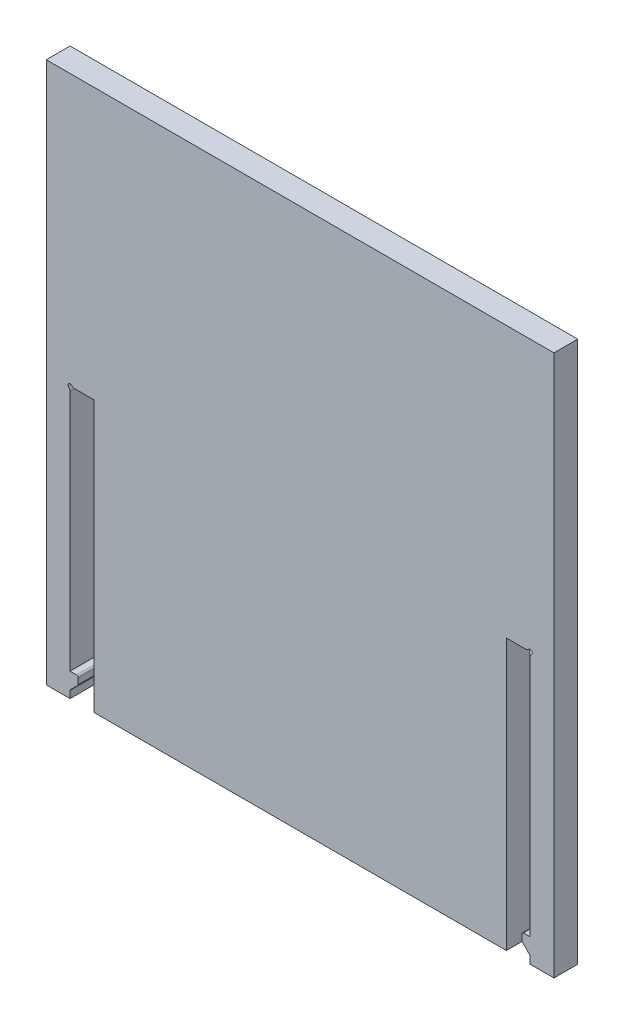
from build123d import *

# Parameters (mm, degrees)
SKETCH1_W            = 62.519999928
SKETCH1_H            = 66.675
BOSS_EXTRUDE1_DEPTH  = 2.929999982
SKETCH2_W            = 2.929999982
SKETCH2_H            = 33.3375
CUT_EXTRUDE1_DEPTH   = 3.929999982
BOSS_EXTRUDE2_DEPTH  = 2.93
FILLET1_R            = 0.2
SKETCH5_R            = 0.25
CUT_EXTRUDE2_DEPTH   = 3.93
FILLET2_R            = 0.5
FILLET1_OF_MIRROR1_R = 0.2
FILLET2_OF_MIRROR1_R = 0.5


with BuildPart() as part:
    # Sketch1 → Boss-Extrude1 (new body)
    with BuildSketch(Plane.XY):
        Rectangle(SKETCH1_W, SKETCH1_H)
    extrude(amount=BOSS_EXTRUDE1_DEPTH)

    # Sketch2 → Cut-Extrude1 (cut, through all)
    with BuildSketch(Plane.XY.offset(2.929999982)):
        with Locations((-26.864999991, -16.66875)):
            Rectangle(SKETCH2_W, SKETCH2_H)
    cut_extrude1 = extrude(amount=-CUT_EXTRUDE1_DEPTH, mode=Mode.SUBTRACT)

    # Sketch4 → Boss-Extrude2 (add)
    with BuildSketch(Plane.XY.offset(2.929999982)):
        Polygon((-27.330001982, -30.407500018), (-28.329999982, -30.407500018), (-28.329999982, -32.407498018), (-27.330001982, -31.407500018), align=None)
    boss_extrude2 = extrude(amount=-BOSS_EXTRUDE2_DEPTH)

    # Fillet1
    fillet1_edges = [part.edges().sort_by_distance(p)[0] for p in [
        (-27.330001982, -30.407500018, 1.464999982),
        (-28.329999982, -32.407498018, 1.464999982),
        (-27.330001982, -31.407500018, 1.464999982),
    ]]
    fillet(fillet1_edges, radius=FILLET1_R)

    # Sketch5 → Cut-Extrude2 (cut, through all)
    with BuildSketch(Plane.XY.offset(2.929999982)):
        with Locations((-28.329999982, 0)):
            Circle(SKETCH5_R)
    cut_extrude2 = extrude(amount=-CUT_EXTRUDE2_DEPTH, mode=Mode.SUBTRACT)

    # Fillet2
    fillet2_edges = [part.edges().sort_by_distance(p)[0] for p in [
        (-28.079999982, 0, 1.464999991),
        (-28.329999982, -0.25, 1.464999991),
    ]]
    fillet(fillet2_edges, radius=FILLET2_R)

    # Mirror1: Cut-Extrude1, Boss-Extrude2, Cut-Extrude2 across plane
    add(cut_extrude1.mirror(Plane(origin=(0, 0, 0), x_dir=(0, 0, 1), z_dir=(1, 0, 0))), mode=Mode.SUBTRACT)
    add(boss_extrude2.mirror(Plane(origin=(0, 0, 0), x_dir=(0, 0, 1), z_dir=(1, 0, 0))))
    add(cut_extrude2.mirror(Plane(origin=(0, 0, 0), x_dir=(0, 0, 1), z_dir=(1, 0, 0))), mode=Mode.SUBTRACT)

    # Fillet1 of Mirror1
    fillet1_of_mirror1_edges = [part.edges().sort_by_distance(p)[0] for p in [
        (27.330001982, -30.407500018, 1.464999982),
        (28.329999982, -32.407498018, 1.464999982),
        (27.330001982, -31.407500018, 1.464999982),
    ]]
    fillet(fillet1_of_mirror1_edges, radius=FILLET1_OF_MIRROR1_R)

    # Fillet2 of Mirror1
    fillet2_of_mirror1_edges = [part.edges().sort_by_distance(p)[0] for p in [
        (28.079999982, 0, 1.464999991),
        (28.329999982, -0.25, 1.464999991),
    ]]
    fillet(fillet2_of_mirror1_edges, radius=FILLET2_OF_MIRROR1_R)


solid = part.part
